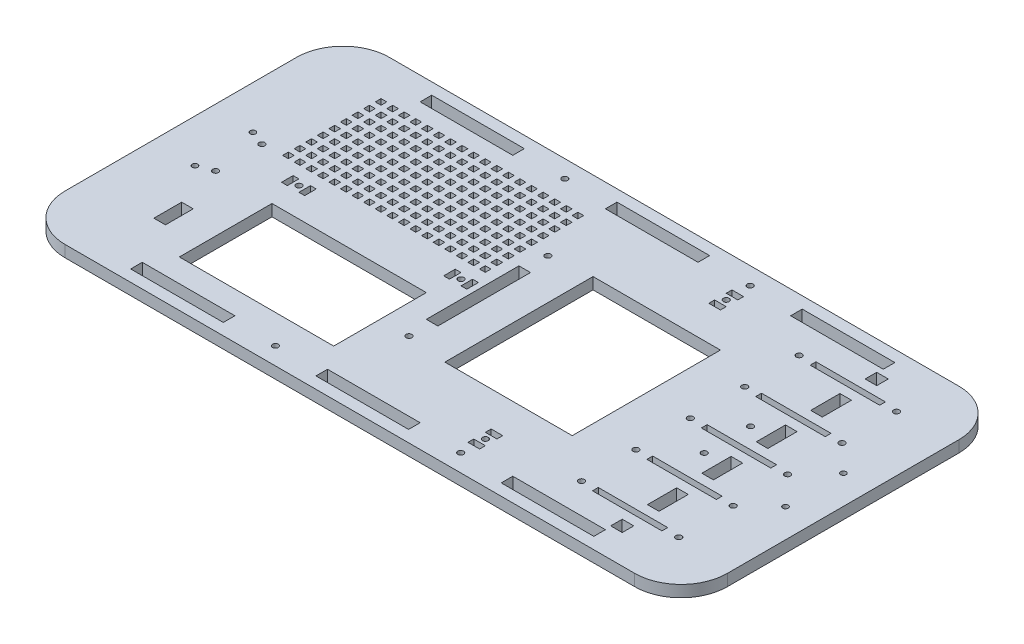
from build123d import *

# Parameters (mm, degrees)
BASEEXTRUDE_DEPTH  = 6.35
SKETCH6_R          = 1.5
MAINMOUNTCUT_DEPTH = 6.35
SKETCH7_R          = 1.6
SKETCH7_W          = 50.8
SKETCH7_H          = 6.35
WALLCUT_DEPTH      = 7.35
SKETCH8_R          = 1.6
SKETCH8_W          = 38.1
SKETCH8_H          = 3.175
WIREMOUNTCUT_DEPTH = 7.35
SKETCH9_R          = 1.6
CUT_EXTRUDE3_DEPTH = 7.35
SKETCH11_R         = 1.6
SKETCH11_W         = 6.35
SKETCH11_H         = 3.175
SKETCH11_H_2       = 50.8
CUT_EXTRUDE4_DEPTH = 7.35
SKETCH13_R         = 1.6
SKETCH13_W         = 3.175
SKETCH13_H         = 6.35
CUT_EXTRUDE5_DEPTH = 7.35
SKETCH14_W         = 6.35
SKETCH14_H         = 15.24
CUT_EXTRUDE6_DEPTH = 7.35
SKETCH15_W         = 69.85
SKETCH15_H         = 81.28
SKETCH15_W_2       = 84.641855902
SKETCH15_H_2       = 50.8
SKETCH15_W_3       = 3.175
SKETCH15_H_3       = 3.175
CUT_EXTRUDE7_DEPTH = 7.35
SKETCH16_W         = 6.35
SKETCH16_H         = 6.35
CUT_EXTRUDE8_DEPTH = 7.35


with BuildPart() as part:
    # Sketch3 → BaseExtrude (new body)
    with BuildSketch(Plane(origin=(0, 0, 0), x_dir=(1, 0, 0), z_dir=(0, 1, 0))):
        with BuildLine():
            Line((-156.21, -88.9), (156.21, -88.9))
            ThreePointArc((156.21, -88.9), (174.170512242, -81.460512242), (181.61, -63.5))
            Line((181.61, -63.5), (181.61, 63.5))
            ThreePointArc((181.61, 63.5), (174.170512242, 81.460512242), (156.21, 88.9))
            Line((156.21, 88.9), (-156.21, 88.9))
            ThreePointArc((-156.21, 88.9), (-174.170512242, 81.460512242), (-181.61, 63.5))
            Line((-181.61, 63.5), (-181.61, -63.5))
            ThreePointArc((-181.61, -63.5), (-174.170512242, -81.460512242), (-156.21, -88.9))
        make_face()
    extrude(amount=-BASEEXTRUDE_DEPTH)

    # Sketch6 → MainMountCut (cut)
    with BuildSketch(Plane(origin=(0, 0, 0), x_dir=(1, 0, 0), z_dir=(0, 1, 0))):
        with Locations((-157.988, 15.875)):
            Circle(SKETCH6_R)
        with Locations((-157.988, -15.875)):
            Circle(SKETCH6_R)
        with Locations((165.862, -15.875)):
            Circle(SKETCH6_R)
        with Locations((165.862, 15.875)):
            Circle(SKETCH6_R)
    extrude(amount=-MAINMOUNTCUT_DEPTH, mode=Mode.SUBTRACT)

    # Sketch7 → WallCut (cut, through all)
    with BuildSketch(Plane(origin=(0, 0, 0), x_dir=(1, 0, 0), z_dir=(0, 1, 0))):
        with Locations((51.223333333, 79.375)):
            Circle(SKETCH7_R)
        with Locations((-50.376666667, 79.375)):
            Circle(SKETCH7_R)
        with Locations((-50.376666667, -79.375)):
            Circle(SKETCH7_R)
        with Locations((51.223333333, -79.375)):
            Circle(SKETCH7_R)
        with Locations((102.023333333, -79.375)):
            Rectangle(SKETCH7_W, SKETCH7_H)
        with Locations((0.423333333, -79.375)):
            Rectangle(SKETCH7_W, SKETCH7_H)
        with Locations((-101.176666667, -79.375)):
            Rectangle(SKETCH7_W, SKETCH7_H)
        with Locations((102.023333333, 79.375)):
            Rectangle(SKETCH7_W, SKETCH7_H)
        with Locations((0.423333333, 79.375)):
            Rectangle(SKETCH7_W, SKETCH7_H)
        with Locations((-101.176666667, 79.375)):
            Rectangle(SKETCH7_W, SKETCH7_H)
    extrude(amount=-WALLCUT_DEPTH, mode=Mode.SUBTRACT)

    # Sketch8 → WireMountCut (cut, through all)
    with BuildSketch(Plane(origin=(0, 0, 0), x_dir=(1, 0, 0), z_dir=(0, 1, 0))):
        with Locations((151.13, -59.69)):
            Circle(SKETCH8_R)
        with Locations((151.13, -29.845)):
            Circle(SKETCH8_R)
        with Locations((151.13, 0)):
            Circle(SKETCH8_R)
        with Locations((151.13, 29.845)):
            Circle(SKETCH8_R)
        with Locations((151.13, 59.69)):
            Circle(SKETCH8_R)
        with Locations((97.79, 59.69)):
            Circle(SKETCH8_R)
        with Locations((97.79, 29.845)):
            Circle(SKETCH8_R)
        with Locations((97.79, 0)):
            Circle(SKETCH8_R)
        with Locations((97.79, -29.845)):
            Circle(SKETCH8_R)
        with Locations((97.79, -59.69)):
            Circle(SKETCH8_R)
        with Locations((124.46, -59.69)):
            Rectangle(SKETCH8_W, SKETCH8_H)
        with Locations((124.46, -29.845)):
            Rectangle(SKETCH8_W, SKETCH8_H)
        with Locations((124.46, 0)):
            Rectangle(SKETCH8_W, SKETCH8_H)
        with Locations((124.46, 29.845)):
            Rectangle(SKETCH8_W, SKETCH8_H)
        with Locations((124.46, 59.69)):
            Rectangle(SKETCH8_W, SKETCH8_H)
    extrude(amount=-WIREMOUNTCUT_DEPTH, mode=Mode.SUBTRACT)

    # Sketch9 → Cut-Extrude3 (cut, through all)
    with BuildSketch(Plane(origin=(0, 0, 0), x_dir=(1, 0, 0), z_dir=(0, 1, 0))):
        with Locations((118.11, 12.7)):
            Circle(SKETCH9_R)
        with Locations((118.11, -12.7)):
            Circle(SKETCH9_R)
        with Locations((-149.86, -12.7)):
            Circle(SKETCH9_R)
        with Locations((-149.86, 12.7)):
            Circle(SKETCH9_R)
    extrude(amount=-CUT_EXTRUDE3_DEPTH, mode=Mode.SUBTRACT)

    # Sketch11 → Cut-Extrude4 (cut, through all)
    with BuildSketch(Plane(origin=(0, 0, 0), x_dir=(1, 0, 0), z_dir=(0, 1, 0))):
        with Locations((51.435, -66.04)):
            Circle(SKETCH11_R)
        with Locations((51.435, 66.04)):
            Circle(SKETCH11_R)
        with Locations((-18.415, -38.1)):
            Circle(SKETCH11_R)
        with Locations((-18.415, 38.1)):
            Circle(SKETCH11_R)
        with Locations((51.435, 70.8025)):
            Rectangle(SKETCH11_W, SKETCH11_H)
        with Locations((51.435, 61.2775)):
            Rectangle(SKETCH11_W, SKETCH11_H)
        with Locations((51.435, -70.8025)):
            Rectangle(SKETCH11_W, SKETCH11_H)
        with Locations((-18.415, 0)):
            Rectangle(SKETCH11_W, SKETCH11_H_2)
        with Locations((51.435, -61.2775)):
            Rectangle(SKETCH11_W, SKETCH11_H)
    extrude(amount=-CUT_EXTRUDE4_DEPTH, mode=Mode.SUBTRACT)

    # Sketch13 → Cut-Extrude5 (cut, through all)
    with BuildSketch(Plane(origin=(0, 0, 0), x_dir=(1, 0, 0), z_dir=(0, 1, 0))):
        with Locations((-120.0404, 3.175)):
            Circle(SKETCH13_R)
        with Locations((-31.1404, 3.175)):
            Circle(SKETCH13_R)
        with Locations((-26.3779, 3.175)):
            Rectangle(SKETCH13_W, SKETCH13_H)
        with Locations((-35.9029, 3.175)):
            Rectangle(SKETCH13_W, SKETCH13_H)
        with Locations((-115.2779, 3.175)):
            Rectangle(SKETCH13_W, SKETCH13_H)
        with Locations((-124.8029, 3.175)):
            Rectangle(SKETCH13_W, SKETCH13_H)
    extrude(amount=-CUT_EXTRUDE5_DEPTH, mode=Mode.SUBTRACT)

    # Sketch14 → Cut-Extrude6 (cut, through all)
    with BuildSketch(Plane(origin=(0, 0, 0), x_dir=(1, 0, 0), z_dir=(0, 1, 0))):
        with Locations((-141.156855902, -44.45)):
            Rectangle(SKETCH14_W, SKETCH14_H)
    extrude(amount=-CUT_EXTRUDE6_DEPTH, mode=Mode.SUBTRACT)

    # Sketch15 → Cut-Extrude7 (cut, through all)
    with BuildSketch(Plane(origin=(0, 0, 0), x_dir=(1, 0, 0), z_dir=(0, 1, 0))):
        with Locations((38.735, 0)):
            Rectangle(SKETCH15_W, SKETCH15_H)
        with Locations((-76.610927951, -38.1)):
            Rectangle(SKETCH15_W_2, SKETCH15_H_2)
        with Locations((-35.668318241, 65.44012146)):
            Rectangle(SKETCH15_W_3, SKETCH15_H_3)
        with Locations((-29.318318241, 65.44012146)):
            Rectangle(SKETCH15_W_3, SKETCH15_H_3)
        with Locations((-42.018318241, 65.44012146)):
            Rectangle(SKETCH15_W_3, SKETCH15_H_3)
        with Locations((-48.368318241, 65.44012146)):
            Rectangle(SKETCH15_W_3, SKETCH15_H_3)
        with Locations((-54.718318241, 65.44012146)):
            Rectangle(SKETCH15_W_3, SKETCH15_H_3)
        with Locations((-61.068318241, 65.44012146)):
            Rectangle(SKETCH15_W_3, SKETCH15_H_3)
        with Locations((-67.418318241, 65.44012146)):
            Rectangle(SKETCH15_W_3, SKETCH15_H_3)
        with Locations((-73.768318241, 65.44012146)):
            Rectangle(SKETCH15_W_3, SKETCH15_H_3)
        with Locations((-80.118318241, 65.44012146)):
            Rectangle(SKETCH15_W_3, SKETCH15_H_3)
        with Locations((-86.468318241, 65.44012146)):
            Rectangle(SKETCH15_W_3, SKETCH15_H_3)
        with Locations((-92.818318241, 65.44012146)):
            Rectangle(SKETCH15_W_3, SKETCH15_H_3)
        with Locations((-99.168318241, 65.44012146)):
            Rectangle(SKETCH15_W_3, SKETCH15_H_3)
        with Locations((-105.518318241, 65.44012146)):
            Rectangle(SKETCH15_W_3, SKETCH15_H_3)
        with Locations((-111.868318241, 65.44012146)):
            Rectangle(SKETCH15_W_3, SKETCH15_H_3)
        with Locations((-118.218318241, 65.44012146)):
            Rectangle(SKETCH15_W_3, SKETCH15_H_3)
        with Locations((-124.568318241, 65.44012146)):
            Rectangle(SKETCH15_W_3, SKETCH15_H_3)
        with Locations((-130.918318241, 65.44012146)):
            Rectangle(SKETCH15_W_3, SKETCH15_H_3)
        with Locations((-137.268318241, 65.44012146)):
            Rectangle(SKETCH15_W_3, SKETCH15_H_3)
        with Locations((-35.668318241, 59.09012146)):
            Rectangle(SKETCH15_W_3, SKETCH15_H_3)
        with Locations((-42.018318241, 59.09012146)):
            Rectangle(SKETCH15_W_3, SKETCH15_H_3)
        with Locations((-48.368318241, 59.09012146)):
            Rectangle(SKETCH15_W_3, SKETCH15_H_3)
        with Locations((-54.718318241, 59.09012146)):
            Rectangle(SKETCH15_W_3, SKETCH15_H_3)
        with Locations((-61.068318241, 59.09012146)):
            Rectangle(SKETCH15_W_3, SKETCH15_H_3)
        with Locations((-67.418318241, 59.09012146)):
            Rectangle(SKETCH15_W_3, SKETCH15_H_3)
        with Locations((-73.768318241, 59.09012146)):
            Rectangle(SKETCH15_W_3, SKETCH15_H_3)
        with Locations((-80.118318241, 59.09012146)):
            Rectangle(SKETCH15_W_3, SKETCH15_H_3)
        with Locations((-86.468318241, 59.09012146)):
            Rectangle(SKETCH15_W_3, SKETCH15_H_3)
        with Locations((-92.818318241, 59.09012146)):
            Rectangle(SKETCH15_W_3, SKETCH15_H_3)
        with Locations((-99.168318241, 59.09012146)):
            Rectangle(SKETCH15_W_3, SKETCH15_H_3)
        with Locations((-105.518318241, 59.09012146)):
            Rectangle(SKETCH15_W_3, SKETCH15_H_3)
        with Locations((-111.868318241, 59.09012146)):
            Rectangle(SKETCH15_W_3, SKETCH15_H_3)
        with Locations((-118.218318241, 59.09012146)):
            Rectangle(SKETCH15_W_3, SKETCH15_H_3)
        with Locations((-124.568318241, 59.09012146)):
            Rectangle(SKETCH15_W_3, SKETCH15_H_3)
        with Locations((-130.918318241, 59.09012146)):
            Rectangle(SKETCH15_W_3, SKETCH15_H_3)
        with Locations((-137.268318241, 59.09012146)):
            Rectangle(SKETCH15_W_3, SKETCH15_H_3)
        with Locations((-35.668318241, 52.74012146)):
            Rectangle(SKETCH15_W_3, SKETCH15_H_3)
        with Locations((-42.018318241, 52.74012146)):
            Rectangle(SKETCH15_W_3, SKETCH15_H_3)
        with Locations((-48.368318241, 52.74012146)):
            Rectangle(SKETCH15_W_3, SKETCH15_H_3)
        with Locations((-54.718318241, 52.74012146)):
            Rectangle(SKETCH15_W_3, SKETCH15_H_3)
        with Locations((-61.068318241, 52.74012146)):
            Rectangle(SKETCH15_W_3, SKETCH15_H_3)
        with Locations((-67.418318241, 52.74012146)):
            Rectangle(SKETCH15_W_3, SKETCH15_H_3)
        with Locations((-73.768318241, 52.74012146)):
            Rectangle(SKETCH15_W_3, SKETCH15_H_3)
        with Locations((-80.118318241, 52.74012146)):
            Rectangle(SKETCH15_W_3, SKETCH15_H_3)
        with Locations((-86.468318241, 52.74012146)):
            Rectangle(SKETCH15_W_3, SKETCH15_H_3)
        with Locations((-92.818318241, 52.74012146)):
            Rectangle(SKETCH15_W_3, SKETCH15_H_3)
        with Locations((-99.168318241, 52.74012146)):
            Rectangle(SKETCH15_W_3, SKETCH15_H_3)
        with Locations((-105.518318241, 52.74012146)):
            Rectangle(SKETCH15_W_3, SKETCH15_H_3)
        with Locations((-111.868318241, 52.74012146)):
            Rectangle(SKETCH15_W_3, SKETCH15_H_3)
        with Locations((-118.218318241, 52.74012146)):
            Rectangle(SKETCH15_W_3, SKETCH15_H_3)
        with Locations((-124.568318241, 52.74012146)):
            Rectangle(SKETCH15_W_3, SKETCH15_H_3)
        with Locations((-130.918318241, 52.74012146)):
            Rectangle(SKETCH15_W_3, SKETCH15_H_3)
        with Locations((-137.268318241, 52.74012146)):
            Rectangle(SKETCH15_W_3, SKETCH15_H_3)
        with Locations((-35.668318241, 46.39012146)):
            Rectangle(SKETCH15_W_3, SKETCH15_H_3)
        with Locations((-42.018318241, 46.39012146)):
            Rectangle(SKETCH15_W_3, SKETCH15_H_3)
        with Locations((-48.368318241, 46.39012146)):
            Rectangle(SKETCH15_W_3, SKETCH15_H_3)
        with Locations((-54.718318241, 46.39012146)):
            Rectangle(SKETCH15_W_3, SKETCH15_H_3)
        with Locations((-61.068318241, 46.39012146)):
            Rectangle(SKETCH15_W_3, SKETCH15_H_3)
        with Locations((-67.418318241, 46.39012146)):
            Rectangle(SKETCH15_W_3, SKETCH15_H_3)
        with Locations((-73.768318241, 46.39012146)):
            Rectangle(SKETCH15_W_3, SKETCH15_H_3)
        with Locations((-80.118318241, 46.39012146)):
            Rectangle(SKETCH15_W_3, SKETCH15_H_3)
        with Locations((-86.468318241, 46.39012146)):
            Rectangle(SKETCH15_W_3, SKETCH15_H_3)
        with Locations((-92.818318241, 46.39012146)):
            Rectangle(SKETCH15_W_3, SKETCH15_H_3)
        with Locations((-99.168318241, 46.39012146)):
            Rectangle(SKETCH15_W_3, SKETCH15_H_3)
        with Locations((-105.518318241, 46.39012146)):
            Rectangle(SKETCH15_W_3, SKETCH15_H_3)
        with Locations((-111.868318241, 46.39012146)):
            Rectangle(SKETCH15_W_3, SKETCH15_H_3)
        with Locations((-118.218318241, 46.39012146)):
            Rectangle(SKETCH15_W_3, SKETCH15_H_3)
        with Locations((-124.568318241, 46.39012146)):
            Rectangle(SKETCH15_W_3, SKETCH15_H_3)
        with Locations((-130.918318241, 46.39012146)):
            Rectangle(SKETCH15_W_3, SKETCH15_H_3)
        with Locations((-137.268318241, 46.39012146)):
            Rectangle(SKETCH15_W_3, SKETCH15_H_3)
        with Locations((-35.668318241, 40.04012146)):
            Rectangle(SKETCH15_W_3, SKETCH15_H_3)
        with Locations((-42.018318241, 40.04012146)):
            Rectangle(SKETCH15_W_3, SKETCH15_H_3)
        with Locations((-48.368318241, 40.04012146)):
            Rectangle(SKETCH15_W_3, SKETCH15_H_3)
        with Locations((-54.718318241, 40.04012146)):
            Rectangle(SKETCH15_W_3, SKETCH15_H_3)
        with Locations((-61.068318241, 40.04012146)):
            Rectangle(SKETCH15_W_3, SKETCH15_H_3)
        with Locations((-67.418318241, 40.04012146)):
            Rectangle(SKETCH15_W_3, SKETCH15_H_3)
        with Locations((-73.768318241, 40.04012146)):
            Rectangle(SKETCH15_W_3, SKETCH15_H_3)
        with Locations((-80.118318241, 40.04012146)):
            Rectangle(SKETCH15_W_3, SKETCH15_H_3)
        with Locations((-86.468318241, 40.04012146)):
            Rectangle(SKETCH15_W_3, SKETCH15_H_3)
        with Locations((-92.818318241, 40.04012146)):
            Rectangle(SKETCH15_W_3, SKETCH15_H_3)
        with Locations((-99.168318241, 40.04012146)):
            Rectangle(SKETCH15_W_3, SKETCH15_H_3)
        with Locations((-105.518318241, 40.04012146)):
            Rectangle(SKETCH15_W_3, SKETCH15_H_3)
        with Locations((-111.868318241, 40.04012146)):
            Rectangle(SKETCH15_W_3, SKETCH15_H_3)
        with Locations((-118.218318241, 40.04012146)):
            Rectangle(SKETCH15_W_3, SKETCH15_H_3)
        with Locations((-124.568318241, 40.04012146)):
            Rectangle(SKETCH15_W_3, SKETCH15_H_3)
        with Locations((-130.918318241, 40.04012146)):
            Rectangle(SKETCH15_W_3, SKETCH15_H_3)
        with Locations((-137.268318241, 40.04012146)):
            Rectangle(SKETCH15_W_3, SKETCH15_H_3)
        with Locations((-35.668318241, 33.69012146)):
            Rectangle(SKETCH15_W_3, SKETCH15_H_3)
        with Locations((-42.018318241, 33.69012146)):
            Rectangle(SKETCH15_W_3, SKETCH15_H_3)
        with Locations((-48.368318241, 33.69012146)):
            Rectangle(SKETCH15_W_3, SKETCH15_H_3)
        with Locations((-54.718318241, 33.69012146)):
            Rectangle(SKETCH15_W_3, SKETCH15_H_3)
        with Locations((-61.068318241, 33.69012146)):
            Rectangle(SKETCH15_W_3, SKETCH15_H_3)
        with Locations((-67.418318241, 33.69012146)):
            Rectangle(SKETCH15_W_3, SKETCH15_H_3)
        with Locations((-73.768318241, 33.69012146)):
            Rectangle(SKETCH15_W_3, SKETCH15_H_3)
        with Locations((-80.118318241, 33.69012146)):
            Rectangle(SKETCH15_W_3, SKETCH15_H_3)
        with Locations((-86.468318241, 33.69012146)):
            Rectangle(SKETCH15_W_3, SKETCH15_H_3)
        with Locations((-92.818318241, 33.69012146)):
            Rectangle(SKETCH15_W_3, SKETCH15_H_3)
        with Locations((-99.168318241, 33.69012146)):
            Rectangle(SKETCH15_W_3, SKETCH15_H_3)
        with Locations((-105.518318241, 33.69012146)):
            Rectangle(SKETCH15_W_3, SKETCH15_H_3)
        with Locations((-111.868318241, 33.69012146)):
            Rectangle(SKETCH15_W_3, SKETCH15_H_3)
        with Locations((-118.218318241, 33.69012146)):
            Rectangle(SKETCH15_W_3, SKETCH15_H_3)
        with Locations((-124.568318241, 33.69012146)):
            Rectangle(SKETCH15_W_3, SKETCH15_H_3)
        with Locations((-130.918318241, 33.69012146)):
            Rectangle(SKETCH15_W_3, SKETCH15_H_3)
        with Locations((-137.268318241, 33.69012146)):
            Rectangle(SKETCH15_W_3, SKETCH15_H_3)
        with Locations((-35.668318241, 27.34012146)):
            Rectangle(SKETCH15_W_3, SKETCH15_H_3)
        with Locations((-42.018318241, 27.34012146)):
            Rectangle(SKETCH15_W_3, SKETCH15_H_3)
        with Locations((-48.368318241, 27.34012146)):
            Rectangle(SKETCH15_W_3, SKETCH15_H_3)
        with Locations((-54.718318241, 27.34012146)):
            Rectangle(SKETCH15_W_3, SKETCH15_H_3)
        with Locations((-61.068318241, 27.34012146)):
            Rectangle(SKETCH15_W_3, SKETCH15_H_3)
        with Locations((-67.418318241, 27.34012146)):
            Rectangle(SKETCH15_W_3, SKETCH15_H_3)
        with Locations((-73.768318241, 27.34012146)):
            Rectangle(SKETCH15_W_3, SKETCH15_H_3)
        with Locations((-80.118318241, 27.34012146)):
            Rectangle(SKETCH15_W_3, SKETCH15_H_3)
        with Locations((-86.468318241, 27.34012146)):
            Rectangle(SKETCH15_W_3, SKETCH15_H_3)
        with Locations((-92.818318241, 27.34012146)):
            Rectangle(SKETCH15_W_3, SKETCH15_H_3)
        with Locations((-99.168318241, 27.34012146)):
            Rectangle(SKETCH15_W_3, SKETCH15_H_3)
        with Locations((-105.518318241, 27.34012146)):
            Rectangle(SKETCH15_W_3, SKETCH15_H_3)
        with Locations((-111.868318241, 27.34012146)):
            Rectangle(SKETCH15_W_3, SKETCH15_H_3)
        with Locations((-118.218318241, 27.34012146)):
            Rectangle(SKETCH15_W_3, SKETCH15_H_3)
        with Locations((-124.568318241, 27.34012146)):
            Rectangle(SKETCH15_W_3, SKETCH15_H_3)
        with Locations((-130.918318241, 27.34012146)):
            Rectangle(SKETCH15_W_3, SKETCH15_H_3)
        with Locations((-137.268318241, 27.34012146)):
            Rectangle(SKETCH15_W_3, SKETCH15_H_3)
        with Locations((-35.668318241, 20.99012146)):
            Rectangle(SKETCH15_W_3, SKETCH15_H_3)
        with Locations((-42.018318241, 20.99012146)):
            Rectangle(SKETCH15_W_3, SKETCH15_H_3)
        with Locations((-48.368318241, 20.99012146)):
            Rectangle(SKETCH15_W_3, SKETCH15_H_3)
        with Locations((-54.718318241, 20.99012146)):
            Rectangle(SKETCH15_W_3, SKETCH15_H_3)
        with Locations((-61.068318241, 20.99012146)):
            Rectangle(SKETCH15_W_3, SKETCH15_H_3)
        with Locations((-67.418318241, 20.99012146)):
            Rectangle(SKETCH15_W_3, SKETCH15_H_3)
        with Locations((-73.768318241, 20.99012146)):
            Rectangle(SKETCH15_W_3, SKETCH15_H_3)
        with Locations((-80.118318241, 20.99012146)):
            Rectangle(SKETCH15_W_3, SKETCH15_H_3)
        with Locations((-86.468318241, 20.99012146)):
            Rectangle(SKETCH15_W_3, SKETCH15_H_3)
        with Locations((-92.818318241, 20.99012146)):
            Rectangle(SKETCH15_W_3, SKETCH15_H_3)
        with Locations((-99.168318241, 20.99012146)):
            Rectangle(SKETCH15_W_3, SKETCH15_H_3)
        with Locations((-105.518318241, 20.99012146)):
            Rectangle(SKETCH15_W_3, SKETCH15_H_3)
        with Locations((-111.868318241, 20.99012146)):
            Rectangle(SKETCH15_W_3, SKETCH15_H_3)
        with Locations((-118.218318241, 20.99012146)):
            Rectangle(SKETCH15_W_3, SKETCH15_H_3)
        with Locations((-124.568318241, 20.99012146)):
            Rectangle(SKETCH15_W_3, SKETCH15_H_3)
        with Locations((-130.918318241, 20.99012146)):
            Rectangle(SKETCH15_W_3, SKETCH15_H_3)
        with Locations((-137.268318241, 20.99012146)):
            Rectangle(SKETCH15_W_3, SKETCH15_H_3)
        with Locations((-35.668318241, 14.64012146)):
            Rectangle(SKETCH15_W_3, SKETCH15_H_3)
        with Locations((-42.018318241, 14.64012146)):
            Rectangle(SKETCH15_W_3, SKETCH15_H_3)
        with Locations((-48.368318241, 14.64012146)):
            Rectangle(SKETCH15_W_3, SKETCH15_H_3)
        with Locations((-54.718318241, 14.64012146)):
            Rectangle(SKETCH15_W_3, SKETCH15_H_3)
        with Locations((-61.068318241, 14.64012146)):
            Rectangle(SKETCH15_W_3, SKETCH15_H_3)
        with Locations((-67.418318241, 14.64012146)):
            Rectangle(SKETCH15_W_3, SKETCH15_H_3)
        with Locations((-73.768318241, 14.64012146)):
            Rectangle(SKETCH15_W_3, SKETCH15_H_3)
        with Locations((-80.118318241, 14.64012146)):
            Rectangle(SKETCH15_W_3, SKETCH15_H_3)
        with Locations((-86.468318241, 14.64012146)):
            Rectangle(SKETCH15_W_3, SKETCH15_H_3)
        with Locations((-92.818318241, 14.64012146)):
            Rectangle(SKETCH15_W_3, SKETCH15_H_3)
        with Locations((-99.168318241, 14.64012146)):
            Rectangle(SKETCH15_W_3, SKETCH15_H_3)
        with Locations((-105.518318241, 14.64012146)):
            Rectangle(SKETCH15_W_3, SKETCH15_H_3)
        with Locations((-111.868318241, 14.64012146)):
            Rectangle(SKETCH15_W_3, SKETCH15_H_3)
        with Locations((-118.218318241, 14.64012146)):
            Rectangle(SKETCH15_W_3, SKETCH15_H_3)
        with Locations((-124.568318241, 14.64012146)):
            Rectangle(SKETCH15_W_3, SKETCH15_H_3)
        with Locations((-130.918318241, 14.64012146)):
            Rectangle(SKETCH15_W_3, SKETCH15_H_3)
        with Locations((-137.268318241, 14.64012146)):
            Rectangle(SKETCH15_W_3, SKETCH15_H_3)
        with Locations((-29.318318241, 59.09012146)):
            Rectangle(SKETCH15_W_3, SKETCH15_H_3)
        with Locations((-29.318318241, 52.74012146)):
            Rectangle(SKETCH15_W_3, SKETCH15_H_3)
        with Locations((-29.318318241, 46.39012146)):
            Rectangle(SKETCH15_W_3, SKETCH15_H_3)
        with Locations((-29.318318241, 40.04012146)):
            Rectangle(SKETCH15_W_3, SKETCH15_H_3)
        with Locations((-29.318318241, 33.69012146)):
            Rectangle(SKETCH15_W_3, SKETCH15_H_3)
        with Locations((-29.318318241, 27.34012146)):
            Rectangle(SKETCH15_W_3, SKETCH15_H_3)
        with Locations((-29.318318241, 20.99012146)):
            Rectangle(SKETCH15_W_3, SKETCH15_H_3)
        with Locations((-29.318318241, 14.64012146)):
            Rectangle(SKETCH15_W_3, SKETCH15_H_3)
    extrude(amount=-CUT_EXTRUDE7_DEPTH, mode=Mode.SUBTRACT)

    # Sketch16 → Cut-Extrude8 (cut, through all)
    with BuildSketch(Plane(origin=(0, 0, 0), x_dir=(1, 0, 0), z_dir=(0, 1, 0))):
        with Locations((130.233680409, 69.773422755)):
            Rectangle(SKETCH16_W, SKETCH16_H)
        Polygon((133.408680409, 43.103422755), (133.408680409, 52.781577245), (127.058680409, 52.781577245), (127.058680409, 43.103422755), (127.058680409, 36.753422755), (133.408680409, 36.753422755), align=None)
        Polygon((133.408680409, 13.258422755), (133.408680409, 6.908422755), (127.058680409, 6.908422755), (127.058680409, 13.258422755), (127.058680409, 22.936577245), (133.408680409, 22.936577245), align=None)
        Polygon((133.408680409, -16.586577245), (133.408680409, -22.936577245), (127.058680409, -22.936577245), (127.058680409, -16.586577245), (127.058680409, -6.908422755), (133.408680409, -6.908422755), align=None)
        Polygon((133.408680409, -46.431577245), (133.408680409, -52.781577245), (127.058680409, -52.781577245), (127.058680409, -46.431577245), (127.058680409, -36.753422755), (133.408680409, -36.753422755), align=None)
        with Locations((130.233680409, -69.773422755)):
            Rectangle(SKETCH16_W, SKETCH16_H)
    extrude(amount=-CUT_EXTRUDE8_DEPTH, mode=Mode.SUBTRACT)


solid = part.part
